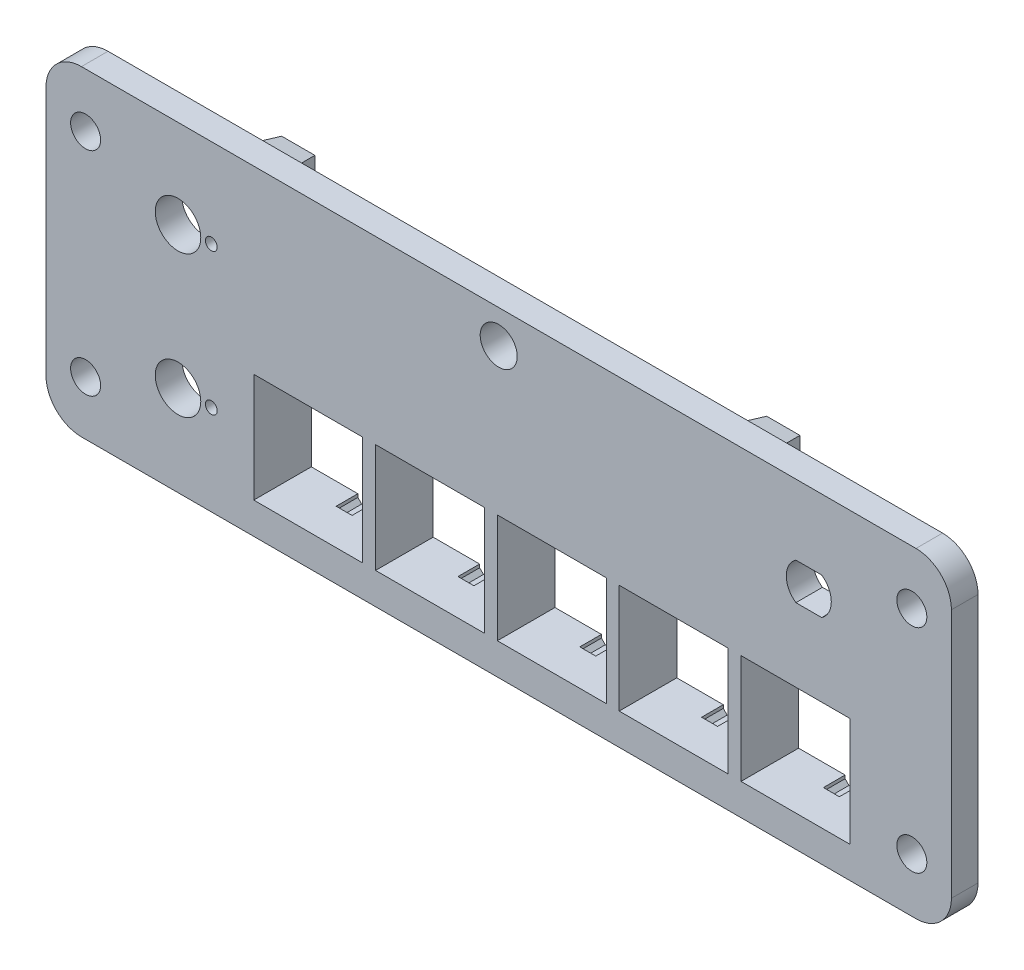
from build123d import *

# Parameters (mm, degrees)
BOSS_EXTRUDE1_DEPTH       = 3.81
CUT_EXTRUDE1_DEPTH        = 4.81
F_6_CLEARANCE_HOLE1_D     = 4.3053
CUT_EXTRUDE2_DEPTH        = 4.81
SKETCH9_R                 = 3.2639
SKETCH9_R_2               = 0.8509
CUT_EXTRUDE3_DEPTH        = 4.81
F_6_32_TAPPED_HOLE1_D     = 2.7051
SKETCH16_W                = 15.621
SKETCH16_H                = 15.621
SKETCH16_W_2              = 4.7625
SKETCH16_H_2              = 4.7625
BOSS_EXTRUDE2_DEPTH       = 8.255
CUT_EXTRUDE5_START        = -3.1115
CUT_EXTRUDE5_DEPTH        = 3.1115
HOLE1_AT_2_COUNT          = 2
HOLE1_AT_2_PITCH          = 25.305626968
HOLE1_AT_3_COUNT          = 2
HOLE1_AT_3_PITCH          = 75.470417856
HOLE1_AT_4_COUNT          = 2
HOLE1_AT_4_PITCH          = 69.5325
F_2_CLEARANCE_HOLE1_D     = 2.2606
F_2_CLEARANCE_HOLE1_DEPTH = 3.302
DRAFT1_ANGLE              = 10
DRAFT2_ANGLE              = 10
DRAFT3_ANGLE              = 10


with BuildPart() as part:
    # Sketch1 → Boss-Extrude1 (new body)
    with BuildSketch(Plane.XY):
        with BuildLine():
            Line((-59.817, -45.974), (59.817, -45.974))
            ThreePointArc((59.817, -45.974), (63.409102448, -44.486102448), (64.897, -40.894))
            Line((64.897, -40.894), (64.897, -5.08))
            ThreePointArc((64.897, -5.08), (63.409102448, -1.487897552), (59.817, 0))
            Line((59.817, 0), (-59.817, 0))
            ThreePointArc((-59.817, 0), (-63.409102448, -1.487897552), (-64.897, -5.08))
            Line((-64.897, -5.08), (-64.897, -40.894))
            ThreePointArc((-64.897, -40.894), (-63.409102448, -44.486102448), (-59.817, -45.974))
        make_face()
    extrude(amount=BOSS_EXTRUDE1_DEPTH)

    # Sketch5 → Cut-Extrude1 (cut, through all)
    with BuildSketch(Plane.XY.offset(3.81)):
        with BuildLine():
            Line((52.07, -41.91), (52.07, -25.4))
            ThreePointArc((52.07, -25.4), (51.698025612, -24.501974388), (50.8, -24.13))
            Line((50.8, -24.13), (-35.56, -24.13))
            ThreePointArc((-35.56, -24.13), (-36.458025612, -24.501974388), (-36.83, -25.4))
            Line((-36.83, -25.4), (-36.83, -41.91))
            ThreePointArc((-36.83, -41.91), (-36.458025612, -42.808025612), (-35.56, -43.18))
            Line((-35.56, -43.18), (50.8, -43.18))
            ThreePointArc((50.8, -43.18), (51.698025612, -42.808025612), (52.07, -41.91))
        make_face()
    extrude(amount=-CUT_EXTRUDE1_DEPTH, mode=Mode.SUBTRACT)

    # #6 Clearance Hole1 (through all)
    with Locations(Plane.XY.offset(3.81)):
        with Locations((59.2201, -7.747), (59.2201, -38.227), (-59.2201, -38.227), (-59.2201, -7.747)):
            Hole(F_6_CLEARANCE_HOLE1_D / 2)

    # Sketch8 → Cut-Extrude2 (cut, through all)
    with BuildSketch(Plane.XY.offset(3.81)):
        with BuildLine():
            Line((46.301414346, -10.0584), (44.45, -10.0584))
            Line((44.45, -10.0584), (44.45, -15.3416))
            Line((44.45, -15.3416), (46.301414346, -15.3416))
            ThreePointArc((46.301414346, -15.3416), (47.6758, -12.7), (46.301414346, -10.0584))
        make_face()
        with BuildLine():
            Line((44.45, -10.0584), (42.598585654, -10.0584))
            ThreePointArc((42.598585654, -10.0584), (41.2242, -12.7), (42.598585654, -15.3416))
            Line((42.598585654, -15.3416), (44.45, -15.3416))
            Line((44.45, -15.3416), (44.45, -10.0584))
        make_face()
    extrude(amount=-CUT_EXTRUDE2_DEPTH, mode=Mode.SUBTRACT)

    # Sketch9 → Cut-Extrude3 (cut, through all)
    with BuildSketch(Plane.XY.offset(3.81)):
        with Locations((-45.974, -33.02)):
            Circle(SKETCH9_R)
        with Locations((-41.1988, -33.02)):
            Circle(SKETCH9_R_2)
        with Locations((-45.974, -12.7)):
            Circle(SKETCH9_R)
        with Locations((-41.1988, -12.7)):
            Circle(SKETCH9_R_2)
    extrude(amount=-CUT_EXTRUDE3_DEPTH, mode=Mode.SUBTRACT)

    # #6-32 Tapped Hole1 (through all)
    with Locations(Plane.XY.offset(3.81)):
        with Locations((0, -4.757510223)):
            Hole(F_6_32_TAPPED_HOLE1_D / 2)

    # Sketch16 → Boss-Extrude2 (add)
    with BuildSketch(Plane.XY.offset(3.81)):
        Polygon((-39.37, -43.18), (53.6575, -43.18), (53.6575, -24.13), (16.025, -24.13), (16.025, -19.3675), (11.2625, -19.3675), (11.2625, -24.13), (-39.37, -24.13), align=None)
        with Locations((42.545, -33.655)):
            Rectangle(SKETCH16_W, SKETCH16_H, mode=Mode.SUBTRACT)
        with Locations((-9.8425, -33.655)):
            Rectangle(SKETCH16_W, SKETCH16_H, mode=Mode.SUBTRACT)
        with Locations((25.0825, -33.655)):
            Rectangle(SKETCH16_W, SKETCH16_H, mode=Mode.SUBTRACT)
        with Locations((7.62, -33.655)):
            Rectangle(SKETCH16_W, SKETCH16_H, mode=Mode.SUBTRACT)
        with Locations((-27.305, -33.655)):
            Rectangle(SKETCH16_W, SKETCH16_H, mode=Mode.SUBTRACT)
        with Locations((32.54375, -4.92125)):
            Rectangle(SKETCH16_W_2, SKETCH16_H_2)
        with Locations((-36.98875, -4.92125)):
            Rectangle(SKETCH16_W_2, SKETCH16_H_2)
    extrude(amount=-BOSS_EXTRUDE2_DEPTH)

    # Sketch17 → Cut-Extrude5 (cut)
    with BuildSketch(Plane(origin=(0, 0, -4.445), x_dir=(-1, 0, 0), z_dir=(0, 0, -1)).offset(CUT_EXTRUDE5_START)):
        Polygon((-37.87775, -26.0985), (-37.87775, -25.38007951), (-38.42932951, -24.8285), (-39.61217049, -24.8285), (-40.16375, -25.38007951), (-40.16375, -26.0985), (-44.92625, -26.0985), (-44.92625, -25.38007951), (-45.47782951, -24.8285), (-46.66067049, -24.8285), (-47.21225, -25.38007951), (-47.21225, -26.0985), (-50.1015, -26.0985), (-50.1015, -41.2115), (-43.688, -41.2115), (-43.688, -41.92992049), (-43.13642049, -42.4815), (-41.95357951, -42.4815), (-41.402, -41.92992049), (-41.402, -41.2115), (-34.9885, -41.2115), (-34.9885, -26.0985), align=None)
        Polygon((-20.41525, -26.0985), (-20.41525, -25.38007951), (-20.96682951, -24.8285), (-22.14967049, -24.8285), (-22.70125, -25.38007951), (-22.70125, -26.0985), (-27.46375, -26.0985), (-27.46375, -25.38007951), (-28.01532951, -24.8285), (-29.19817049, -24.8285), (-29.74975, -25.38007951), (-29.74975, -26.0985), (-32.639, -26.0985), (-32.639, -41.2115), (-26.2255, -41.2115), (-26.2255, -41.92992049), (-25.67392049, -42.4815), (-24.49107951, -42.4815), (-23.9395, -41.92992049), (-23.9395, -41.2115), (-17.526, -41.2115), (-17.526, -26.0985), align=None)
        Polygon((-2.95275, -26.0985), (-2.95275, -25.38007951), (-3.50432951, -24.8285), (-4.68717049, -24.8285), (-5.23875, -25.38007951), (-5.23875, -26.0985), (-10.00125, -26.0985), (-10.00125, -25.38007951), (-10.55282951, -24.8285), (-11.73567049, -24.8285), (-12.28725, -25.38007951), (-12.28725, -26.0985), (-15.1765, -26.0985), (-15.1765, -41.2115), (-8.763, -41.2115), (-8.763, -41.92992049), (-8.21142049, -42.4815), (-7.02857951, -42.4815), (-6.477, -41.92992049), (-6.477, -41.2115), (-0.0635, -41.2115), (-0.0635, -26.0985), align=None)
        Polygon((14.50975, -26.0985), (14.50975, -25.38007951), (13.95817049, -24.8285), (12.77532951, -24.8285), (12.22375, -25.38007951), (12.22375, -26.0985), (7.46125, -26.0985), (7.46125, -25.38007951), (6.90967049, -24.8285), (5.72682951, -24.8285), (5.17525, -25.38007951), (5.17525, -26.0985), (2.286, -26.0985), (2.286, -41.2115), (8.6995, -41.2115), (8.6995, -41.92992049), (9.25107951, -42.4815), (10.43392049, -42.4815), (10.9855, -41.92992049), (10.9855, -41.2115), (17.399, -41.2115), (17.399, -26.0985), align=None)
        Polygon((31.97225, -26.0985), (31.97225, -25.38007951), (31.42067049, -24.8285), (30.23782951, -24.8285), (29.68625, -25.38007951), (29.68625, -26.0985), (24.92375, -26.0985), (24.92375, -25.38007951), (24.37217049, -24.8285), (23.18932951, -24.8285), (22.63775, -25.38007951), (22.63775, -26.0985), (19.7485, -26.0985), (19.7485, -41.2115), (26.162, -41.2115), (26.162, -41.92992049), (26.71357951, -42.4815), (27.89642049, -42.4815), (28.448, -41.92992049), (28.448, -41.2115), (34.8615, -41.2115), (34.8615, -26.0985), align=None)
    extrude(amount=CUT_EXTRUDE5_DEPTH, mode=Mode.SUBTRACT)

    # Sketch19 → Hole1 (revolve, cut)
    with BuildSketch(Plane(origin=(32.54375, -4.92125, -4.445), x_dir=(0, 1, 0), z_dir=(1, 0, 0))):
        Polygon((0, 0), (0, 2.921), (1.4986, 2.921), (1.6383, 0), align=None)
    hole1 = revolve(axis=Axis((32.54375, -4.92125, 105.555), (0, 0, -1)), mode=Mode.SUBTRACT)

    # Hole1 at 2: Hole1 ×2
    with Locations(*[Vector(-0.746869462, -0.664970681, 0) * (i * HOLE1_AT_2_PITCH) for i in range(1, HOLE1_AT_2_COUNT)]):
        add(hole1, mode=Mode.SUBTRACT)

    # Hole1 at 3: Hole1 ×2
    with Locations(*[Vector(-0.924686811, -0.380728646, 0) * (i * HOLE1_AT_3_PITCH) for i in range(1, HOLE1_AT_3_COUNT)]):
        add(hole1, mode=Mode.SUBTRACT)

    # Hole1 at 4: Hole1 ×2
    with Locations(*[(-i * HOLE1_AT_4_PITCH, 0, 0) for i in range(1, HOLE1_AT_4_COUNT)]):
        add(hole1, mode=Mode.SUBTRACT)

    # Sketch21 → Hole2 (revolve, cut)
    with BuildSketch(Plane(origin=(0, -4.757510223, 3.81), x_dir=(0, -1, 0), z_dir=(1, 0, 0))):
        Polygon((0, 0), (0, 3.81), (2.5273, 3.81), (2.6543, 0), align=None)
    revolve(axis=Axis((0, -4.757510223, -106.19), (0, 0, 1)), mode=Mode.SUBTRACT)

    # #2 Clearance Hole1
    with Locations(Plane(origin=(0, 0, -1.524), x_dir=(-1, 0, 0), z_dir=(0, 0, -1))):
        with Locations((37.24275, -33.655), (36.98875, -4.92125), (-13.64375, -21.74875), (-32.54375, -4.92125)):
            Hole(F_2_CLEARANCE_HOLE1_D / 2, depth=F_2_CLEARANCE_HOLE1_DEPTH)

    # Draft1
    draft1_faces = [part.faces().sort_by_distance(p)[0] for p in [
        (53.6575, -33.655, -2.2225),
        (34.84125, -24.13, -2.2225),
        (-39.37, -33.655, -2.2225),
        (-14.05375, -24.13, -2.2225),
        (11.2625, -21.74875, -2.2225),
        (13.64375, -19.3675, -2.2225),
        (16.025, -21.74875, -2.2225),
    ]]
    draft(draft1_faces, Plane(origin=(-31.52175, -36.67125, -4.445), x_dir=(-1, 0, 0), z_dir=(0, 0, -1)), DRAFT1_ANGLE)

    # Draft2
    draft2_faces = [part.faces().sort_by_distance(p)[0] for p in [
        (7.14375, -43.18, -2.216310494),
    ]]
    draft(draft2_faces, Plane(origin=(-31.52175, -36.67125, -4.445), x_dir=(-1, 0, 0), z_dir=(0, 0, -1)), DRAFT2_ANGLE)

    # Draft3
    draft3_faces = [part.faces().sort_by_distance(p)[0] for p in [
        (32.54375, -2.54, -2.2225),
        (34.925, -4.92125, -2.2225),
        (32.54375, -7.3025, -2.2225),
        (30.1625, -4.92125, -2.2225),
        (-36.98875, -7.3025, -2.2225),
        (-39.37, -4.92125, -2.2225),
        (-36.98875, -2.54, -2.2225),
        (-34.6075, -4.92125, -2.2225),
    ]]
    draft(draft3_faces, Plane(origin=(-31.52175, -36.67125, -4.445), x_dir=(-1, 0, 0), z_dir=(0, 0, -1)), DRAFT3_ANGLE)


solid = part.part
